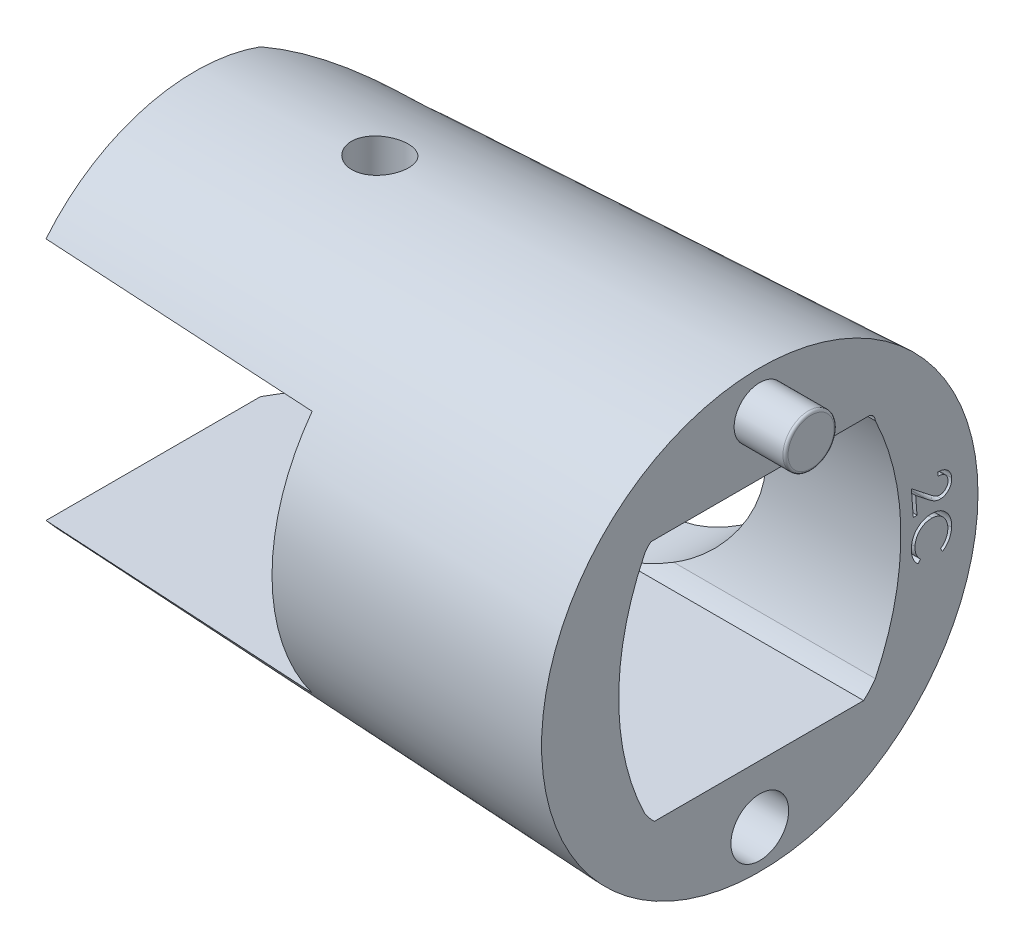
from build123d import *

# Parameters (mm, degrees)
SKETCH2_R               = 7.5
SKETCH3_R               = 8.5
SKETCH4_W               = 15.537816222
SKETCH4_H               = 9.5
CUT_EXTRUDE1_DEPTH      = 10
CUT_EXTRUDE1_DEPTH_BACK = 10
CUT_EXTRUDE2_DEPTH      = 10
CUT_EXTRUDE2_DEPTH_BACK = 10
SKETCH6_R               = 1.05
CUT_EXTRUDE3_DEPTH      = 26.069902429
CUT_EXTRUDE3_DEPTH_BACK = 26.069902429
CUT_EXTRUDE4_DEPTH      = 26.069902429
CUT_EXTRUDE4_DEPTH_BACK = 12
CROQUIS1_R              = 1
SALIENTE_EXTRUIR1_DEPTH = 2
CROQUIS1_4_R            = 1.125
CORTAR_EXTRUIR1_DEPTH   = 2.15
REDONDEO1_R             = 0.1
CORTAR_EXTRUIR2_DEPTH   = 5
CORTAR_EXTRUIR9_DEPTH   = 20
CORTAR_EXTRUIR10_DEPTH  = 20
CORTAR_EXTRUIR11_DEPTH  = 26
CORTAR_EXTRUIR12_DEPTH  = 32.5
CORTAR_EXTRUIR13_DEPTH  = 2


with BuildPart() as part:
    # Sketch2 → Loft1 section 0
    with BuildSketch(Plane(origin=(-22, 0, 0), x_dir=(0, 0, -1), z_dir=(1, 0, 0))):
        Circle(SKETCH2_R)
    # Sketch3 → Loft1 section 1
    with BuildSketch(Plane(origin=(0, 0, 0), x_dir=(0, 0, -1), z_dir=(1, 0, 0))):
        Circle(SKETCH3_R)
    loft()

    # Sketch4 → Cut-Extrude1 (cut, two sides)
    with BuildSketch(Plane.XY) as cut_extrude1_sk:
        with Locations((-18.768908111, 0)):
            Rectangle(SKETCH4_W, SKETCH4_H)
    extrude(amount=CUT_EXTRUDE1_DEPTH, mode=Mode.SUBTRACT)
    extrude(cut_extrude1_sk.sketch, amount=-CUT_EXTRUDE1_DEPTH_BACK, mode=Mode.SUBTRACT)

    # Sketch5 → Cut-Extrude2 (cut, two sides)
    with BuildSketch(Plane(origin=(0, 0, 0), x_dir=(1, 0, 0), z_dir=(0, 1, 0))) as cut_extrude2_sk:
        with BuildLine():
            Line((-11, -8.501479666), (-11, -6.777720856))
            Line((-11, -6.777720856), (-23.002284576, -6.042868806))
            Line((-23.002284576, -6.042868806), (-23.023054805, -1.488266586))
            ThreePointArc((-23.023054805, -1.488266586), (-20.642688282, 4.38478963), (-14.821907997, 6.89027381))
            Line((-14.821907997, 6.89027381), (-11, 6.954632602))
            Line((-11, 6.954632602), (-11, 8.501479666))
            Line((-11, 8.501479666), (-26, 8.501479666))
            Line((-26, 8.501479666), (-26, -8.501479666))
            Line((-26, -8.501479666), (-11, -8.501479666))
        make_face()
    extrude(amount=CUT_EXTRUDE2_DEPTH, mode=Mode.SUBTRACT)
    extrude(cut_extrude2_sk.sketch, amount=-CUT_EXTRUDE2_DEPTH_BACK, mode=Mode.SUBTRACT)

    # Sketch6 → Cut-Extrude3 (cut, two sides)
    with BuildSketch(Plane(origin=(0, 0, 0), x_dir=(1, 0, 0), z_dir=(0, 1, 0))) as cut_extrude3_sk:
        with Locations(Location((-15.3, 0.5, 0), (0, 0, 135.099030436))):
            Circle(SKETCH6_R)
    extrude(amount=CUT_EXTRUDE3_DEPTH, mode=Mode.SUBTRACT)
    extrude(cut_extrude3_sk.sketch, amount=-CUT_EXTRUDE3_DEPTH_BACK, mode=Mode.SUBTRACT)

    # Sketch8 → Cut-Extrude4 (cut, two sides)
    with BuildSketch(Plane(origin=(0, 0, 0), x_dir=(0, 0, -1), z_dir=(1, 0, 0))) as cut_extrude4_sk:
        with BuildLine():
            Line((-4.499973003, 4.438991315), (4.5, 4.461035448))
            ThreePointArc((4.5, 4.461035448), (5.495701778, 0.1110224), (4.5, -4.238990649))
            Line((4.5, -4.238990649), (-4.499973003, -4.261034782))
            ThreePointArc((-4.499973003, -4.261034782), (-5.495674781, 0.088978266), (-4.499973003, 4.438991315))
        make_face()
    extrude(amount=CUT_EXTRUDE4_DEPTH, mode=Mode.SUBTRACT)
    extrude(cut_extrude4_sk.sketch, amount=-CUT_EXTRUDE4_DEPTH_BACK, mode=Mode.SUBTRACT)

    # Croquis1 → Saliente-Extruir1 (add)
    with BuildSketch(Plane(origin=(0, 0, 0), x_dir=(0, 0, -1), z_dir=(1, 0, 0))):
        with Locations((0, 7)):
            Circle(CROQUIS1_R)
    extrude(amount=SALIENTE_EXTRUIR1_DEPTH)

    # Croquis1_4 → Cortar-Extruir1 (cut)
    with BuildSketch(Plane(origin=(0, 0, 0), x_dir=(0, 0, -1), z_dir=(1, 0, 0))):
        with Locations((0, -7)):
            Circle(CROQUIS1_4_R)
    extrude(amount=-CORTAR_EXTRUIR1_DEPTH, mode=Mode.SUBTRACT)

    # Redondeo1
    redondeo1_edges = [part.edges().sort_by_distance(p)[0] for p in [
        (2, 7, 1),
    ]]
    fillet(redondeo1_edges, radius=REDONDEO1_R)

    # Croquis2 → Cortar-Extruir2 (cut, symmetric)
    with BuildSketch(Plane.XY.offset(-8)):
        with BuildLine():
            Line((-11, 4.75), (-11, -4.75))
            Line((-11, -4.75), (-10, -4.75))
            ThreePointArc((-10, -4.75), (-5.25, 0), (-10, 4.75))
            Line((-10, 4.75), (-11, 4.75))
        make_face()
    extrude(amount=CORTAR_EXTRUIR2_DEPTH, both=True, mode=Mode.SUBTRACT)

    # Croquis8 → Cortar-Extruir9 (cut, symmetric)
    with BuildSketch(Plane.ZY.offset(11)):
        with BuildLine():
            Line((4.230865701, 4.75), (-2.552600615, 4.75))
            Line((-2.552600615, 4.75), (-3, 4.75))
            Line((-3, 4.75), (-3, 4.457361415))
            Line((-3, 4.457361415), (4.499973003, 4.438991315))
            ThreePointArc((4.499973003, 4.438991315), (4.387955834, 4.613995859), (4.230865701, 4.75))
        make_face()
    extrude(amount=CORTAR_EXTRUIR9_DEPTH, both=True, mode=Mode.SUBTRACT)

    # Croquis9 → Cortar-Extruir10 (cut, symmetric)
    with BuildSketch(Plane.ZY.offset(11)):
        with BuildLine():
            Line((4.109333907, -4.75), (-3, -4.75))
            Line((-3, -4.75), (-3, -4.242664682))
            Line((-3, -4.242664682), (4.499973003, -4.261034782))
            ThreePointArc((4.499973003, -4.261034782), (4.319266329, -4.517191759), (4.109333907, -4.75))
        make_face()
    extrude(amount=CORTAR_EXTRUIR10_DEPTH, both=True, mode=Mode.SUBTRACT)

    # Croquis10 → Cortar-Extruir11 (cut, symmetric)
    with BuildSketch(Plane.ZY.offset(22)):
        with BuildLine():
            Line((-3, -4.75), (-4.044513861, -4.75))
            ThreePointArc((-4.044513861, -4.75), (-4.288437853, -4.508918125), (-4.5, -4.238990649))
            Line((-4.5, -4.238990649), (-3, -4.242664682))
            Line((-3, -4.242664682), (-3, -4.75))
        make_face()
    extrude(amount=CORTAR_EXTRUIR11_DEPTH, both=True, mode=Mode.SUBTRACT)

    # Croquis11 → Cortar-Extruir12 (cut, symmetric)
    with BuildSketch(Plane.ZY.offset(22)):
        with BuildLine():
            Line((-3, 4.457361415), (-3, 4.75))
            Line((-3, 4.75), (-4.28314731, 4.75))
            ThreePointArc((-4.28314731, 4.75), (-4.437958226, 4.640326903), (-4.5, 4.461035448))
            Line((-4.5, 4.461035448), (-3, 4.457361415))
        make_face()
    extrude(amount=CORTAR_EXTRUIR12_DEPTH, both=True, mode=Mode.SUBTRACT)

    # Croquis12 → Cortar-Extruir13 (cut)
    with BuildSketch(Plane(origin=(0, 0, 0), x_dir=(0, 0, -1), z_dir=(1, 0, 0))):
        with BuildLine():
            Line((7.121941112, -1.251976095), (7.038106978, -1.129379941))
            add(Edge.make_bspline(
                [(7.038106978, -1.129379941), (7.048914322, -1.121790676), (7.07038722, -1.106711715), (7.100769982, -1.082088663), (7.128866034, -1.05569602), (7.155894489, -1.028846481), (7.180510908, -1.000081226), (7.203396895, -0.970151828), (7.224051609, -0.938644136), (7.243456953, -0.906340653), (7.260417795, -0.872574402), (7.275934861, -0.837982087), (7.289073787, -0.802212727), (7.300194018, -0.765587946), (7.309200952, -0.728043508), (7.316488898, -0.689557299), (7.321534143, -0.650009803), (7.323484841, -0.623281037), (7.324465151, -0.609848691)],
                knots=[0, 0, 0, 0, 1.029282788, 2.045061607, 3.045114409, 4.033393539, 5.013247393, 5.993940816, 6.968429329, 7.948625316, 8.929846988, 9.912093272, 10.902713715, 11.898122757, 12.894235864, 13.911064428, 14.950220729, 16, 16, 16, 16], degree=3))
            add(Edge.make_bspline(
                [(7.324465151, -0.609848691), (7.324920649, -0.595127462), (7.325825623, -0.565879685), (7.324436785, -0.52219455), (7.319693322, -0.479188914), (7.313046614, -0.436753407), (7.302932916, -0.39514457), (7.290311213, -0.354193938), (7.275006034, -0.313921274), (7.256948486, -0.274620832), (7.236663405, -0.236695919), (7.214308912, -0.200522989), (7.190330259, -0.166153524), (7.164229377, -0.133910646), (7.135726519, -0.104163195), (7.105616885, -0.076063723), (7.073582747, -0.04993274), (7.039443759, -0.026184119), (7.003939413, -0.004655683), (6.96699673, 0.014424257), (6.928740338, 0.030969363), (6.889199079, 0.045042915), (6.848363324, 0.056609176), (6.806248978, 0.06512517), (6.76293508, 0.071684108), (6.733541033, 0.073652425), (6.71869592, 0.074646501)],
                knots=[0, 0, 0, 0, 1.039798822, 2.065846673, 3.082689481, 4.093019059, 5.096469231, 6.103079335, 7.11704076, 8.136020852, 9.154804599, 10.151829624, 11.136742132, 12.112010159, 13.077459671, 14.043219951, 15.018487978, 15.993550858, 16.977167645, 17.948195747, 18.926944691, 19.917856259, 20.909675901, 21.920772464, 22.949910865, 24, 24, 24, 24], degree=3))
            add(Edge.make_bspline(
                [(6.71869592, 0.074646501), (6.696351292, 0.075424027), (6.652490066, 0.076950266), (6.587811113, 0.071055445), (6.525499246, 0.060290994), (6.46580979, 0.042516923), (6.408289712, 0.019559831), (6.353770504, -0.010358454), (6.3013669, -0.045516762), (6.252573357, -0.086985257), (6.207372855, -0.132605641), (6.167043152, -0.182054589), (6.132757174, -0.235288714), (6.103685245, -0.291676586), (6.08054493, -0.351567323), (6.062889985, -0.414657806), (6.050220768, -0.481104935), (6.04677554, -0.526762067), (6.045018035, -0.550053018)],
                knots=[0, 0, 0, 0, 1.043408534, 2.04815127, 3.027352765, 3.992629521, 4.951775596, 5.914747976, 6.89185717, 7.894637302, 8.900359903, 9.888240853, 10.869307102, 11.852746619, 12.846680115, 13.862709649, 14.909709746, 16, 16, 16, 16], degree=3))
            add(Edge.make_bspline(
                [(6.045018035, -0.550053018), (6.04434164, -0.575709673), (6.04301193, -0.626147567), (6.050951176, -0.700710596), (6.065995616, -0.772586164), (6.089890777, -0.841474442), (6.120758959, -0.907847222), (6.160559929, -0.970761079), (6.206928152, -1.031838662), (6.243583654, -1.068584576), (6.262265631, -1.087312634)],
                knots=[0, 0, 0, 0, 1.027377692, 2.019700838, 2.996516702, 3.963580858, 4.934816172, 5.922584442, 6.941216727, 8, 8, 8, 8], degree=3))
            Line((6.262265631, -1.087312634), (6.166712747, -1.200293403))
            add(Edge.make_bspline(
                [(6.166712747, -1.200293403), (6.155553926, -1.190223046), (6.133398872, -1.170229059), (6.102715365, -1.137695614), (6.073815852, -1.103954533), (6.047411257, -1.068221852), (6.022606289, -1.031260544), (6.000078947, -0.992541833), (5.97996124, -0.951986357), (5.961649564, -0.910129492), (5.945610873, -0.866837895), (5.932572431, -0.822174855), (5.921307326, -0.776619072), (5.912889019, -0.729949254), (5.907345187, -0.682165751), (5.903591559, -0.633354074), (5.902719985, -0.583391551), (5.904031697, -0.549849252), (5.904693516, -0.532925615)],
                knots=[0, 0, 0, 0, 0.970817637, 1.927490227, 2.88704779, 3.839662342, 4.796334932, 5.76200529, 6.731549468, 7.719832599, 8.712850655, 9.712070208, 10.724468498, 11.743792916, 12.773663195, 13.831379332, 14.905830782, 16, 16, 16, 16], degree=3))
            add(Edge.make_bspline(
                [(5.904693516, -0.532925615), (5.905721406, -0.516783644), (5.907743527, -0.485028256), (5.913746977, -0.438149994), (5.920969003, -0.392662558), (5.93081023, -0.348605897), (5.942025078, -0.30589752), (5.955736972, -0.26466194), (5.970911701, -0.224639462), (5.98838121, -0.186107675), (6.007951697, -0.149140901), (6.029409369, -0.113593476), (6.052446887, -0.079217715), (6.077878013, -0.04641809), (6.105038884, -0.014894623), (6.134584076, 0.014945213), (6.165487124, 0.043866588), (6.187723025, 0.061569722), (6.198864189, 0.07043977)],
                knots=[0, 0, 0, 0, 1.118970159, 2.201300729, 3.268951845, 4.304883787, 5.32370253, 6.323146979, 7.310404983, 8.284387586, 9.248605084, 10.203083394, 11.156554604, 12.110328056, 13.073349131, 14.033972887, 15.01493401, 16, 16, 16, 16], degree=3))
            add(Edge.make_bspline(
                [(6.198864189, 0.07043977), (6.218233429, 0.084655789), (6.256605222, 0.1128187), (6.318496918, 0.147938341), (6.382646552, 0.177218237), (6.449434061, 0.200488126), (6.518754994, 0.217583067), (6.590528875, 0.228715623), (6.664855884, 0.233655513), (6.715088481, 0.232025712), (6.740631016, 0.231196982)],
                knots=[0, 0, 0, 0, 0.997576992, 1.97626848, 2.950285843, 3.924232079, 4.910363112, 5.912728993, 6.938653437, 8, 8, 8, 8], degree=3))
            add(Edge.make_bspline(
                [(6.740631016, 0.231196982), (6.767341132, 0.229134593), (6.820020633, 0.22506701), (6.89679625, 0.209694902), (6.969990365, 0.187767832), (7.039574592, 0.15883891), (7.105359152, 0.122512199), (7.167555966, 0.079287057), (7.226172322, 0.029084056), (7.280364406, -0.027705623), (7.329357229, -0.089399532), (7.371774416, -0.154942962), (7.406823797, -0.223817755), (7.434577916, -0.296021183), (7.455109192, -0.371538452), (7.46804681, -0.450258506), (7.474852172, -0.532122653), (7.472963144, -0.587605285), (7.472001208, -0.615858307)],
                knots=[0, 0, 0, 0, 1.028194631, 2.027875136, 3.000298908, 3.959104741, 4.916427597, 5.881150212, 6.863409353, 7.875588235, 8.891568954, 9.885041864, 10.869167561, 11.854382953, 12.851090717, 13.869341364, 14.915020032, 16, 16, 16, 16], degree=3))
            add(Edge.make_bspline(
                [(7.472001208, -0.615858307), (7.470782113, -0.633103652), (7.46837307, -0.667182022), (7.461618002, -0.717415878), (7.452770221, -0.766223085), (7.440868133, -0.813512345), (7.426908845, -0.859552262), (7.409982576, -0.904051157), (7.390659662, -0.94715903), (7.369165897, -0.988898077), (7.345091725, -1.028722489), (7.319167926, -1.066783786), (7.291367274, -1.102798021), (7.261246317, -1.136612965), (7.229669922, -1.168874708), (7.195405888, -1.198492702), (7.159800681, -1.226669204), (7.13458032, -1.243527529), (7.121941112, -1.251976095)],
                knots=[0, 0, 0, 0, 1.099292429, 2.172301811, 3.221814789, 4.252326073, 5.271911221, 6.279928676, 7.277932967, 8.275123722, 9.263814028, 10.235593553, 11.202705913, 12.154934181, 13.114379618, 14.071390046, 15.033475243, 16, 16, 16, 16], degree=3))
        make_face()
        with BuildLine():
            Line((6.941606695, 1.367566213), (6.930789388, 1.510595059))
            add(Edge.make_bspline(
                [(6.930789388, 1.510595059), (6.948922109, 1.511121659), (6.984533804, 1.512155874), (7.036946042, 1.508116503), (7.087249656, 1.499732521), (7.13533547, 1.48679712), (7.181377187, 1.469613336), (7.225130875, 1.447942175), (7.266575824, 1.421460285), (7.305598714, 1.391067408), (7.341528205, 1.357274991), (7.373491979, 1.320893742), (7.401169501, 1.282078158), (7.424338401, 1.240732983), (7.443343865, 1.196932068), (7.458123724, 1.150758359), (7.468448908, 1.102113113), (7.471769463, 1.068732085), (7.473457657, 1.051760924)],
                knots=[0, 0, 0, 0, 1.098933264, 2.15824607, 3.180281982, 4.186123358, 5.171679262, 6.154538805, 7.139814183, 8.147778671, 9.148476736, 10.125091299, 11.078560773, 12.03266787, 12.992475318, 13.96782475, 14.966827091, 16, 16, 16, 16], degree=3))
            add(Edge.make_bspline(
                [(7.473457657, 1.051760924), (7.474382797, 1.034938749), (7.476189852, 1.002080352), (7.47338291, 0.953545299), (7.466074313, 0.907328591), (7.455226667, 0.862938021), (7.438939597, 0.821134585), (7.419164404, 0.781085316), (7.394625154, 0.743301161), (7.365826219, 0.708328736), (7.33453284, 0.675861865), (7.300783941, 0.647353459), (7.265467954, 0.622470265), (7.228262696, 0.601509632), (7.18906579, 0.584854791), (7.148345003, 0.57136199), (7.105682752, 0.562366786), (7.07655786, 0.559316336), (7.061799003, 0.55777054)],
                knots=[0, 0, 0, 0, 1.125669307, 2.198745875, 3.242399491, 4.250941836, 5.247070536, 6.235290637, 7.232678894, 8.251285347, 9.259916606, 10.243338224, 11.200043489, 12.144413391, 13.09224297, 14.043024596, 15.008314952, 16, 16, 16, 16], degree=3))
            add(Edge.make_bspline(
                [(7.061799003, 0.55777054), (7.040851266, 0.556899207), (6.99932951, 0.555172085), (6.93754324, 0.562644673), (6.877064868, 0.576910409), (6.827897326, 0.596247505), (6.78759364, 0.615765211), (6.754652043, 0.63428584), (6.718929031, 0.655858245), (6.680591582, 0.681126707), (6.639326026, 0.709451691), (6.59545891, 0.741468705), (6.54885775, 0.776603966), (6.5171834, 0.801503211), (6.500801407, 0.814381117)],
                knots=[0, 0, 0, 0, 1.190446576, 2.359654948, 3.525529466, 4.715430966, 5.354780901, 6.071148365, 6.863290755, 7.727368224, 8.681552725, 9.709113993, 10.815152344, 12, 12, 12, 12], degree=3))
            Line((6.500801407, 0.814381117), (6.07231583, 1.15542679))
            Line((6.07231583, 1.15542679), (6.123998522, 0.466724867))
            Line((6.123998522, 0.466724867), (5.980068234, 0.455907559))
            Line((5.980068234, 0.455907559), (5.903746118, 1.469128713))
            Line((5.903746118, 1.469128713), (6.562399965, 0.945390732))
            add(Edge.make_bspline(
                [(6.562399965, 0.945390732), (6.578404207, 0.932643642), (6.609092606, 0.908200887), (6.653612012, 0.873437218), (6.695045849, 0.842563923), (6.733146588, 0.815112295), (6.768122341, 0.791440618), (6.799466495, 0.770673642), (6.828094521, 0.754374522), (6.861017882, 0.736422258), (6.901126903, 0.720578154), (6.949311081, 0.707157205), (6.998447829, 0.701011173), (7.031241054, 0.70207107), (7.047676407, 0.70260227)],
                knots=[0, 0, 0, 0, 1.323813292, 2.538433892, 3.654377033, 4.666869122, 5.576379777, 6.387062736, 7.098442116, 7.707228745, 8.811957234, 9.879370622, 10.937180118, 12, 12, 12, 12], degree=3))
            add(Edge.make_bspline(
                [(7.047676407, 0.70260227), (7.05802563, 0.703694968), (7.078387322, 0.705844807), (7.107959124, 0.712624971), (7.136377811, 0.721882629), (7.163180622, 0.73467793), (7.189066559, 0.749626316), (7.213123167, 0.76794987), (7.236139044, 0.788773693), (7.257544908, 0.812341465), (7.276852857, 0.837883266), (7.293623213, 0.864767619), (7.307026016, 0.892874274), (7.318162863, 0.921803466), (7.325508532, 0.952134791), (7.330272979, 0.983493326), (7.332655712, 1.015991064), (7.331376962, 1.037939823), (7.330729292, 1.049056597)],
                knots=[0, 0, 0, 0, 1.003291776, 1.973937396, 2.921307895, 3.881116622, 4.834138713, 5.800541475, 6.792552851, 7.825519422, 8.867308772, 9.878389621, 10.876829139, 11.867662997, 12.863808164, 13.880691665, 14.926596653, 16, 16, 16, 16], degree=3))
            add(Edge.make_bspline(
                [(7.330729292, 1.049056597), (7.329532167, 1.06070389), (7.327183644, 1.08355359), (7.320201957, 1.116884368), (7.31025673, 1.148449591), (7.29766278, 1.178437165), (7.28193365, 1.206548771), (7.263196761, 1.232767751), (7.241627387, 1.257183722), (7.217756502, 1.280145464), (7.190862573, 1.300397059), (7.162012221, 1.318713028), (7.130532041, 1.333603381), (7.097047691, 1.345967588), (7.061345017, 1.355602589), (7.023445374, 1.36239523), (6.98327164, 1.366703251), (6.955740572, 1.367273473), (6.941606695, 1.367566213)],
                knots=[0, 0, 0, 0, 1.003811897, 1.969281668, 2.914861026, 3.838765388, 4.754162457, 5.671975251, 6.59735636, 7.54535239, 8.507605961, 9.480197412, 10.471579555, 11.488177519, 12.538555824, 13.638934881, 14.787878377, 16, 16, 16, 16], degree=3))
        make_face()
    extrude(amount=-CORTAR_EXTRUIR13_DEPTH, mode=Mode.SUBTRACT)


solid = part.part
